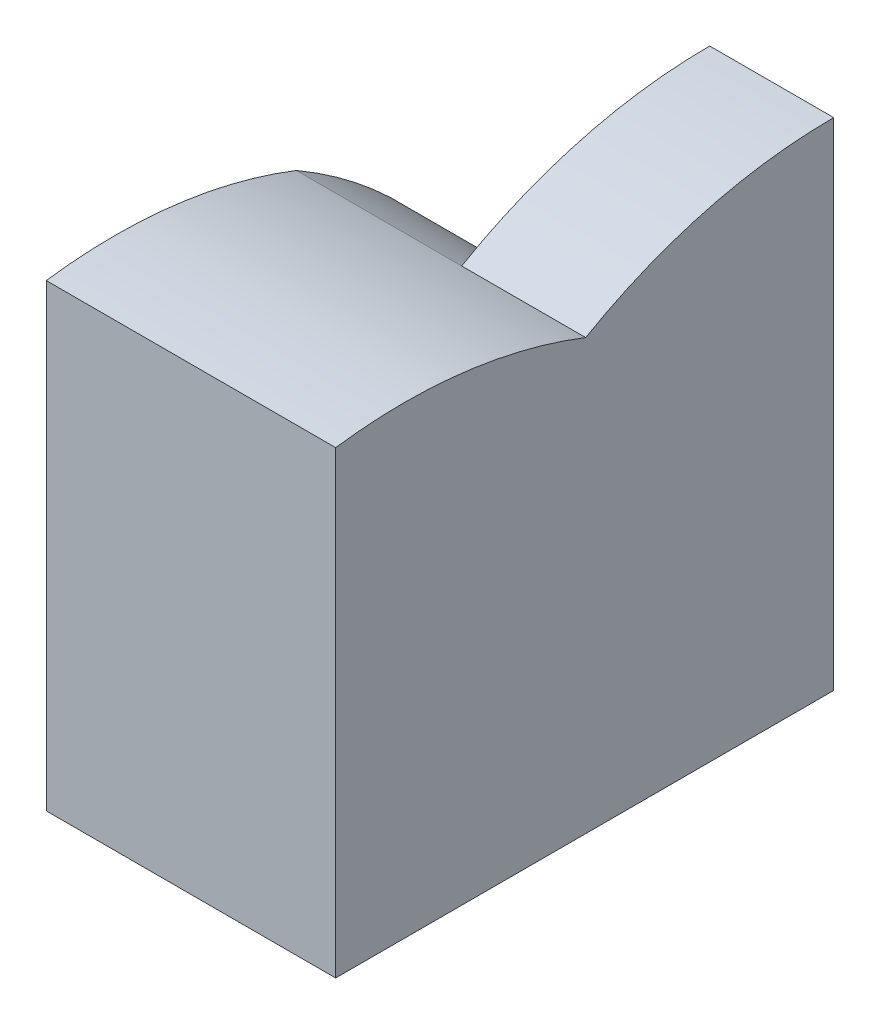
from build123d import *

# Parameters (mm, degrees)
BOSS_EXTRUDE1_DEPTH = 1.5
BOSS_EXTRUDE2_DEPTH = 3.5
BOSS_EXTRUDE3_DEPTH = 3.5
BOSS_EXTRUDE4_DEPTH = 3.5


with BuildPart() as part:
    # Sketch1 → Boss-Extrude1 (new body)
    with BuildSketch(Plane(origin=(0, 0, 0), x_dir=(0, 0, -1), z_dir=(1, 0, 0))):
        with BuildLine():
            Line((-3, 5.196152423), (-3, 0))
            Line((-3, 0), (0, 0))
            Line((0, 0), (0, 6))
            ThreePointArc((0, 6), (-1.552914271, 5.795554958), (-3, 5.196152423))
        make_face()
    extrude(amount=-BOSS_EXTRUDE1_DEPTH)

    # Sketch2 → Boss-Extrude2 (add)
    with BuildSketch(Plane(origin=(0, 0, 0), x_dir=(0, 0, -1), z_dir=(1, 0, 0))):
        with BuildLine():
            Line((-3, 0), (-6.023586903, 0))
            ThreePointArc((-6.023586903, 0), (-5.20953131, 3.004082594), (-3, 5.196152423))
            Line((-3, 5.196152423), (-3, 0))
        make_face()
    extrude(amount=-BOSS_EXTRUDE2_DEPTH)

    # Sketch3 → Boss-Extrude3 (add)
    with BuildSketch(Plane.ZY.offset(3.5)):
        with BuildLine():
            ThreePointArc((3, 5.196152423), (0.803847577, 3), (0, 0))
            Line((0, 0), (3, 0))
            Line((3, 0), (3, 5.196152423))
        make_face()
    extrude(amount=-BOSS_EXTRUDE3_DEPTH)

    # Sketch4 → Boss-Extrude4 (add)
    with BuildSketch(Plane.ZY.offset(3.5)):
        with BuildLine():
            Line((6.023586903, 0), (6.023586903, 5.554981031))
            ThreePointArc((6.023586903, 5.554981031), (4.488653077, 5.570553782), (3, 5.196152423))
            Line((3, 5.196152423), (3, 0))
            Line((3, 0), (6.023586903, 0))
        make_face()
    extrude(amount=-BOSS_EXTRUDE4_DEPTH)


solid = part.part
